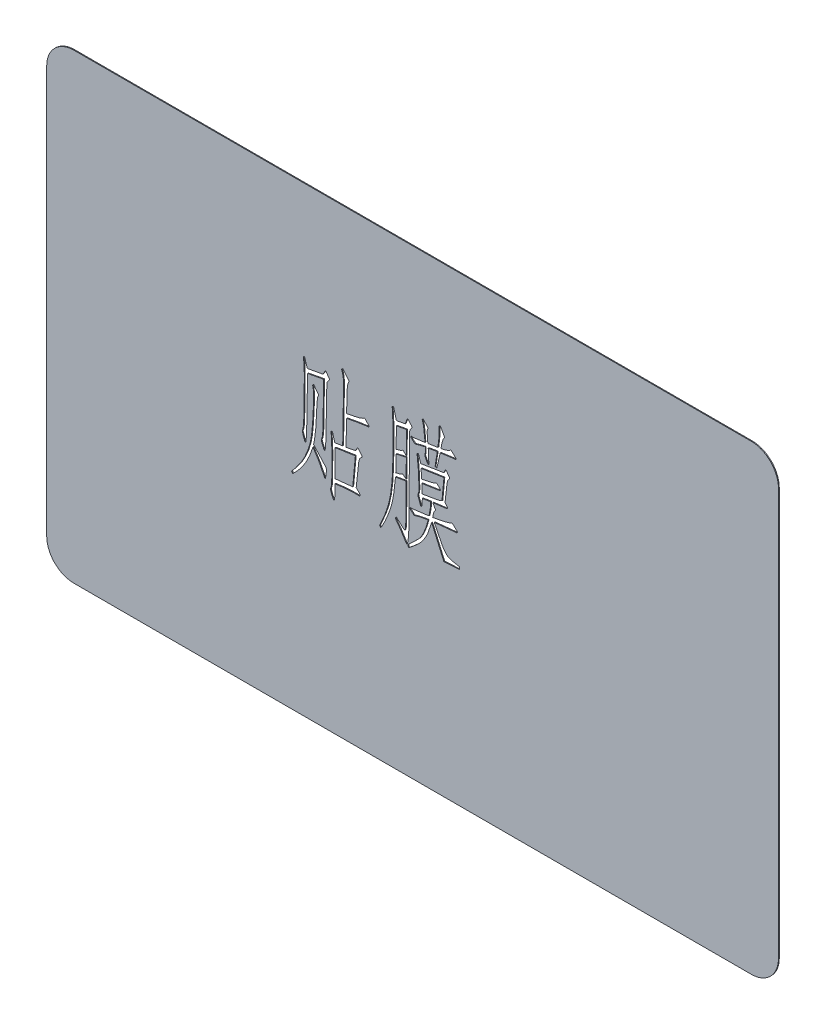
from build123d import *

# Parameters (mm, degrees)
SKETCH_1_W          = 85.6
SKETCH_1_H          = 54
EXTRUDE_1_DEPTH     = 0.1
CUT_EXTRUDE_1_DEPTH = 0.1
FILLET_1_R          = 3.18


with BuildPart() as part:
    # 草图1 → 凸台-拉伸1 (new body)
    with BuildSketch(Plane.XY):
        with Locations((42.8, 27)):
            Rectangle(SKETCH_1_W, SKETCH_1_H)
    extrude(amount=EXTRUDE_1_DEPTH)

    # 草图2 → 切除-拉伸1 (cut)
    with BuildSketch(Plane.XY.offset(0.1)):
        with BuildLine():
            add(Edge.make_bspline(
                [(28.656175286, 24.104684648), (28.735700661, 24.198459974), (28.881749684, 24.370679153), (29.062126573, 24.58276599), (29.199732619, 24.755647068), (29.315265517, 24.912190212), (29.448332239, 25.10102743), (29.540105047, 25.238763146), (29.589480208, 25.312867047)],
                knots=[0, 0, 0, 0, 0.000368874, 0.000677441, 0.00083518, 0.001031645, 0.001261024, 0.001528152, 0.001528152, 0.001528152, 0.001528152], degree=3))
            Line((29.589480208, 25.312867047), (29.864357685, 25.715594513))
            add(Edge.make_bspline(
                [(29.864357685, 25.715594513), (29.906887348, 25.785547825), (30.000429812, 25.939407619), (30.138312694, 26.199102298), (30.280447516, 26.509887767), (30.43607869, 26.856124558), (30.584143752, 27.224018132), (30.709708413, 27.597245925), (30.815624551, 27.962116542), (30.894534474, 28.327868731), (30.958548039, 28.702784693), (31.014348198, 29.099195432), (31.057998689, 29.522910676), (31.092383091, 29.960011392), (31.119951987, 30.382131357), (31.146398119, 30.761315297), (31.165954039, 31.083777027), (31.183160606, 31.447455053), (31.199052983, 31.89069414), (31.214535277, 32.339560662), (31.220062131, 32.707553797), (31.220737523, 32.967558953), (31.215142887, 33.204240258), (31.205136167, 33.353945216), (31.200390074, 33.424948871)],
                knots=[0, 0, 0, 0, 0.000245573, 0.00054013, 0.000881389, 0.001270609, 0.001678957, 0.002070457, 0.002451542, 0.002818101, 0.003192237, 0.003592425, 0.004018816, 0.004469878, 0.004907717, 0.005287866, 0.005610193, 0.005876854, 0.006380096, 0.006940764, 0.007224197, 0.007484159, 0.007720767, 0.007934234, 0.007934234, 0.007934234, 0.007934234], degree=3))
            add(Edge.make_bspline(
                [(31.200390074, 33.424948871), (31.198219884, 33.461875463), (31.194253739, 33.529360919), (31.189471877, 33.619814546), (31.180036791, 33.688498344), (31.174817472, 33.726817851), (31.172689243, 33.742443011)],
                knots=[0, 0, 0, 0, 0.000110988, 0.000202836, 0.000271553, 0.000318866, 0.000318866, 0.000318866, 0.000318866], degree=3))
            Line((31.172689243, 33.742443011), (31.100240915, 34.042890486))
            Line((31.100240915, 34.042890486), (31.215305906, 34.187787141))
            Line((31.215305906, 34.187787141), (31.820462522, 33.367416376))
            add(Edge.make_bspline(
                [(31.820462522, 33.367416376), (31.782372157, 33.304425092), (31.707013567, 33.179802123), (31.663999836, 32.961997333), (31.649619584, 32.739429401), (31.626069297, 32.543004009), (31.612596533, 32.362455698), (31.602121935, 32.189830645), (31.591583828, 31.98099499), (31.577900489, 31.654922207), (31.559860705, 31.223652206), (31.534362206, 30.791311554), (31.519528835, 30.457979141), (31.502729762, 30.232313446), (31.491849623, 30.029648298), (31.480566537, 29.902658024), (31.475267551, 29.843018336)],
                knots=[0, 0, 0, 0, 0.000219227, 0.000433723, 0.000656352, 0.000889792, 0.001026581, 0.001199507, 0.0014086, 0.001653878, 0.002178587, 0.002703503, 0.002953138, 0.003179498, 0.003382331, 0.003561941, 0.003561941, 0.003561941, 0.003561941], degree=3))
            Line((31.475267551, 29.843018336), (31.402819224, 29.210160889))
            add(Edge.make_bspline(
                [(31.402819224, 29.210160889), (31.3947528, 29.127708449), (31.380697761, 28.984042278), (31.357421776, 28.801175523), (31.346241979, 28.6818079), (31.334137534, 28.624856981), (31.330370896, 28.607135106)],
                knots=[0, 0, 0, 0, 0.000248496, 0.000432982, 0.000553237, 0.000607563, 0.000607563, 0.000607563, 0.000607563], degree=3))
            Line((31.330370896, 28.607135106), (31.215305906, 28.074426817))
            Line((31.215305906, 28.074426817), (31.647865037, 27.614166855))
            Line((31.647865037, 27.614166855), (32.135825829, 27.068673567))
            Line((32.135825829, 27.068673567), (32.625917455, 26.521049446))
            add(Edge.make_bspline(
                [(32.625917455, 26.521049446), (32.650826645, 26.489111521), (32.697625327, 26.429107451), (32.721468516, 26.31819724), (32.720973266, 26.206969609), (32.714567041, 26.131087138), (32.711150781, 26.090621149)],
                knots=[0, 0, 0, 0, 0.000119972, 0.0002254, 0.000331963, 0.000453719, 0.000453719, 0.000453719, 0.000453719], degree=3))
            Line((32.711150781, 26.090621149), (32.68344995, 25.745426178))
            Line((32.68344995, 25.745426178), (32.611001623, 25.385315374))
            add(Edge.make_bspline(
                [(32.611001623, 25.385315374), (32.60912093, 25.362192938), (32.606219456, 25.326520379), (32.556566728, 25.294397819), (32.51770981, 25.335818728), (32.50406919, 25.36682775), (32.495936632, 25.385315374)],
                knots=[0, 0, 0, 0, 6.674e-05, 0.000102964, 0.00014558, 0.000208503, 0.000208503, 0.000208503, 0.000208503], degree=3))
            Line((32.495936632, 25.385315374), (32.408572473, 25.572828692))
            add(Edge.make_bspline(
                [(32.408572473, 25.572828692), (32.399408194, 25.592749171), (32.378693042, 25.637777889), (32.342260204, 25.71226904), (32.297730421, 25.800808255), (32.246562043, 25.90307378), (32.189327612, 26.018650817), (32.122629388, 26.146889384), (32.047757735, 26.289136277), (31.940053767, 26.500979245), (31.794070174, 26.777969385), (31.59286763, 27.10947025), (31.379561986, 27.449951736), (31.222737893, 27.673100649), (31.142857579, 27.786764341)],
                knots=[0, 0, 0, 0, 6.578e-05, 0.000148691, 0.00024875, 0.000363102, 0.000491749, 0.000635655, 0.000796727, 0.000973984, 0.001348635, 0.001735632, 0.00213701, 0.002553706, 0.002553706, 0.002553706, 0.002553706], degree=3))
            add(Edge.make_bspline(
                [(31.142857579, 27.786764341), (31.081434308, 27.59056944), (30.961118473, 27.206263086), (30.741628986, 26.655290098), (30.5006678, 26.138704798), (30.227777655, 25.655367598), (29.924866596, 25.193313695), (29.578307092, 24.748208185), (29.196498086, 24.307510205), (28.914561069, 24.03035864), (28.771240276, 23.889470499)],
                knots=[0, 0, 0, 0, 0.000616562, 0.001207722, 0.001777735, 0.002325371, 0.002871451, 0.003433611, 0.004016526, 0.004619224, 0.004619224, 0.004619224, 0.004619224], degree=3))
            Line((28.771240276, 23.889470499), (28.656175286, 24.104684648))
        make_face()
        with BuildLine():
            Line((30.007123507, 36.344190294), (30.152020161, 36.459255285))
            Line((30.152020161, 36.459255285), (30.497215132, 35.410885372))
            Line((30.497215132, 35.410885372), (32.308423315, 35.741164511))
            Line((32.308423315, 35.741164511), (32.553469128, 36.15880781))
            add(Edge.make_bspline(
                [(32.553469128, 36.15880781), (32.560174629, 36.172108302), (32.571906115, 36.195377936), (32.602200299, 36.221016825), (32.640332926, 36.21309835), (32.658116652, 36.196330828), (32.668534118, 36.186508641)],
                knots=[0, 0, 0, 0, 4.495e-05, 7.8641e-05, 0.000108776, 0.000151393, 0.000151393, 0.000151393, 0.000151393], degree=3))
            Line((32.668534118, 36.186508641), (33.04142992, 35.698547848))
            add(Edge.make_bspline(
                [(33.04142992, 35.698547848), (33.050213561, 35.683317124), (33.068447412, 35.651699851), (33.063174347, 35.59630499), (33.055547457, 35.542522288), (33.037504573, 35.511400515), (33.028644921, 35.496118698)],
                knots=[0, 0, 0, 0, 5.1494e-05, 0.000106896, 0.000161221, 0.000213633, 0.000213633, 0.000213633, 0.000213633], degree=3))
            Line((33.028644921, 35.496118698), (32.913579931, 35.353352877))
            add(Edge.make_bspline(
                [(32.913579931, 35.353352877), (32.89544698, 35.33058021), (32.858226066, 35.283835505), (32.821869037, 35.198445726), (32.792182146, 35.103809453), (32.781917528, 34.991266296), (32.777304751, 34.854746089), (32.766764145, 34.682940145), (32.762574379, 34.470447225), (32.756868216, 34.314919003), (32.753767444, 34.230403804)],
                knots=[0, 0, 0, 0, 8.6947e-05, 0.000178474, 0.000276237, 0.000383543, 0.00051581, 0.000686489, 0.000899668, 0.001153381, 0.001153381, 0.001153381, 0.001153381], degree=3))
            Line((32.753767444, 34.230403804), (32.668534118, 29.642720019))
            Line((32.668534118, 29.642720019), (32.638702454, 28.837265087))
            Line((32.638702454, 28.837265087), (32.611001623, 28.519770946))
            Line((32.611001623, 28.519770946), (32.581169959, 28.247024302))
            add(Edge.make_bspline(
                [(32.581169959, 28.247024302), (32.57631288, 28.213730268), (32.568989857, 28.163532819), (32.526779837, 28.08454232), (32.456016144, 28.131709123), (32.436488559, 28.175352552), (32.423488305, 28.204407639)],
                knots=[0, 0, 0, 0, 0.000107496, 0.000162072, 0.000211634, 0.000310345, 0.000310345, 0.000310345, 0.000310345], degree=3))
            Line((32.423488305, 28.204407639), (32.338254979, 28.391920957))
            Line((32.338254979, 28.391920957), (32.25089082, 28.592219274))
            Line((32.25089082, 28.592219274), (32.178442492, 28.779732591))
            Line((32.178442492, 28.779732591), (32.150741661, 28.894797582))
            add(Edge.make_bspline(
                [(32.150741661, 28.894797582), (32.142324743, 28.9156871), (32.128577849, 28.949804813), (32.124573642, 28.996247725), (32.134922254, 29.032471984), (32.150616146, 29.071421318), (32.16904938, 29.125961146), (32.196522349, 29.19345219), (32.220676759, 29.278415469), (32.245532961, 29.379625219), (32.260736277, 29.498258529), (32.272325671, 29.627012341), (32.282603183, 29.753490974), (32.290396159, 29.865113255), (32.298594887, 29.955388097), (32.305452437, 30.007817718), (32.308423315, 30.030531654)],
                knots=[0, 0, 0, 0, 6.7383e-05, 0.000110053, 0.00013641, 0.000179556, 0.000236173, 0.000308997, 0.000397983, 0.000500839, 0.000621377, 0.000756227, 0.000888767, 0.001002022, 0.001091922, 0.00116064, 0.00116064, 0.00116064, 0.00116064], degree=3))
            Line((32.308423315, 30.030531654), (32.36595581, 33.179903058))
            Line((32.36595581, 33.179903058), (32.380871642, 35.265988717))
            Line((32.380871642, 35.265988717), (30.524915963, 34.920793746))
            Line((30.524915963, 34.920793746), (30.439682637, 31.095948232))
            Line((30.439682637, 31.095948232), (30.424766805, 29.75778501))
            Line((30.424766805, 29.75778501), (30.382150142, 28.564518443))
            Line((30.382150142, 28.564518443), (30.352318478, 28.189491807))
            Line((30.352318478, 28.189491807), (30.337402646, 27.974277658))
            add(Edge.make_bspline(
                [(30.337402646, 27.974277658), (30.334811121, 27.94450863), (30.330607715, 27.896223808), (30.276213856, 27.837232075), (30.209136913, 27.876189118), (30.190916031, 27.91846896), (30.179720992, 27.944445994)],
                knots=[0, 0, 0, 0, 8.9925e-05, 0.000145857, 0.000199298, 0.000284451, 0.000284451, 0.000284451, 0.000284451], degree=3))
            Line((30.179720992, 27.944445994), (30.094487666, 28.161790976))
            Line((30.094487666, 28.161790976), (29.992207674, 28.404705956))
            Line((29.992207674, 28.404705956), (29.964506843, 28.54960261))
            Line((29.964506843, 28.54960261), (29.92189018, 28.664667601))
            add(Edge.make_bspline(
                [(29.92189018, 28.664667601), (29.914395771, 28.686453668), (29.901530078, 28.723853922), (29.887146995, 28.784206072), (29.908033844, 28.855025262), (29.944886418, 28.946630012), (29.992352397, 29.067010727), (30.01644413, 29.223792517), (30.038976205, 29.419111216), (30.050118165, 29.664054103), (30.065436184, 29.950928128), (30.074741352, 30.154818454), (30.079571834, 30.260661635)],
                knots=[0, 0, 0, 0, 6.9408e-05, 0.000119152, 0.000182255, 0.000284757, 0.000418202, 0.000567817, 0.000758654, 0.001008407, 0.00130284, 0.001620685, 0.001620685, 0.001620685, 0.001620685], degree=3))
            Line((30.079571834, 30.260661635), (30.107272665, 31.814039005))
            Line((30.107272665, 31.814039005), (30.137104329, 34.475449617))
            add(Edge.make_bspline(
                [(30.137104329, 34.475449617), (30.137562541, 34.557136394), (30.138431229, 34.711999903), (30.132696615, 34.93002434), (30.129654746, 35.121145899), (30.122464673, 35.285889196), (30.11663258, 35.42655222), (30.109418313, 35.543674851), (30.105634735, 35.638193564), (30.101277537, 35.722132504), (30.090704562, 35.819436499), (30.074556347, 35.952635), (30.042163727, 36.132460611), (30.019705962, 36.268161112), (30.007123507, 36.344190294)],
                knots=[0, 0, 0, 0, 0.000245046, 0.000464563, 0.000654255, 0.000818454, 0.000959234, 0.001076604, 0.001170457, 0.001243031, 0.001328689, 0.00146401, 0.001645469, 0.001876672, 0.001876672, 0.001876672, 0.001876672], degree=3))
        make_face()
        with BuildLine():
            Line((33.271559901, 30.448174952), (33.416456556, 30.505707447))
            Line((33.416456556, 30.505707447), (33.704119032, 29.485038366))
            Line((33.704119032, 29.485038366), (34.624638955, 29.642720019))
            Line((34.624638955, 29.642720019), (34.724788113, 35.481202866))
            add(Edge.make_bspline(
                [(34.724788113, 35.481202866), (34.726195142, 35.574957646), (34.728795925, 35.748255977), (34.732579637, 35.987643104), (34.728388993, 36.184483567), (34.717883513, 36.385157463), (34.694326876, 36.592399656), (34.654448183, 36.824874924), (34.591559143, 37.066709254), (34.529172219, 37.23122711), (34.494658133, 37.322242713)],
                knots=[0, 0, 0, 0, 0.000281302, 0.000519965, 0.000718178, 0.000871835, 0.001122677, 0.00134338, 0.001579056, 0.001870887, 0.001870887, 0.001870887, 0.001870887], degree=3))
            Line((34.494658133, 37.322242713), (34.624638955, 37.467139367))
            Line((34.624638955, 37.467139367), (35.372561393, 36.561535276))
            add(Edge.make_bspline(
                [(35.372561393, 36.561535276), (35.346101414, 36.503657871), (35.295155456, 36.392220906), (35.236088637, 36.226019638), (35.191444426, 36.070482307), (35.16794194, 35.918660464), (35.156369721, 35.760453192), (35.146216997, 35.584223221), (35.134841211, 35.383270139), (35.13005267, 35.241142423), (35.12751558, 35.165839559)],
                knots=[0, 0, 0, 0, 0.000190826, 0.000367415, 0.000528698, 0.000675478, 0.000827307, 0.001004486, 0.001205068, 0.001431097, 0.001431097, 0.001431097, 0.001431097], degree=3))
            Line((35.12751558, 35.165839559), (35.084898917, 33.137286395))
            Line((35.084898917, 33.137286395), (36.033119671, 33.324799713))
            add(Edge.make_bspline(
                [(36.033119671, 33.324799713), (36.103553447, 33.33919553), (36.237792625, 33.366632404), (36.428813369, 33.414187357), (36.601062005, 33.462430212), (36.754738872, 33.513362738), (36.889620656, 33.565971072), (37.005322441, 33.622048877), (37.104371968, 33.677049388), (37.158719257, 33.721811016), (37.183769575, 33.742443011)],
                knots=[0, 0, 0, 0, 0.000215646, 0.000410998, 0.000590419, 0.000752138, 0.000896564, 0.001024272, 0.001137927, 0.001235108, 0.001235108, 0.001235108, 0.001235108], degree=3))
            Line((37.183769575, 33.742443011), (37.644029537, 33.252351385))
            add(Edge.make_bspline(
                [(37.644029537, 33.252351385), (37.660197339, 33.230708864), (37.688907708, 33.192276629), (37.702511374, 33.126975625), (37.674514301, 33.069930017), (37.636761086, 33.06662615), (37.616328706, 33.064838068)],
                knots=[0, 0, 0, 0, 8.0409e-05, 0.000142788, 0.000191425, 0.0002488, 0.0002488, 0.0002488, 0.0002488], degree=3))
            Line((37.616328706, 33.064838068), (37.386198725, 33.037137237))
            Line((37.386198725, 33.037137237), (36.307997148, 32.879455583))
            Line((36.307997148, 32.879455583), (35.084898917, 32.649325602))
            Line((35.084898917, 32.649325602), (35.012450589, 29.685336683))
            Line((35.012450589, 29.685336683), (36.105567998, 29.900550831))
            Line((36.105567998, 29.900550831), (36.320782147, 30.245745802))
            add(Edge.make_bspline(
                [(36.320782147, 30.245745802), (36.329484245, 30.259504639), (36.345356186, 30.284599672), (36.385489684, 30.306432104), (36.429937137, 30.292754193), (36.452434133, 30.272554066), (36.465678802, 30.260661635)],
                knots=[0, 0, 0, 0, 4.859e-05, 8.8625e-05, 0.000125839, 0.000179109, 0.000179109, 0.000179109, 0.000179109], degree=3))
            Line((36.465678802, 30.260661635), (36.838574604, 29.800401673))
            add(Edge.make_bspline(
                [(36.838574604, 29.800401673), (36.858060682, 29.773850999), (36.889310125, 29.731272202), (36.904191593, 29.66310264), (36.878735877, 29.622804044), (36.84701538, 29.585606899), (36.798296235, 29.537924753), (36.711899259, 29.461062886), (36.604748701, 29.334552661), (36.535655104, 29.127123362), (36.495133143, 28.881860969), (36.476052532, 28.703892729), (36.465678802, 28.607135106)],
                knots=[0, 0, 0, 0, 9.9398e-05, 0.000159403, 0.000190864, 0.000237791, 0.000307101, 0.000394543, 0.000585559, 0.000795302, 0.001040209, 0.001332001, 0.001332001, 0.001332001, 0.001332001], degree=3))
            Line((36.465678802, 28.607135106), (36.205717157, 26.190770307))
            Line((36.205717157, 26.190770307), (36.638276287, 25.758211176))
            add(Edge.make_bspline(
                [(36.638276287, 25.758211176), (36.649431735, 25.735246803), (36.671280824, 25.690268721), (36.670950334, 25.628095779), (36.656357102, 25.580080991), (36.620886969, 25.55970234), (36.577317955, 25.543596439), (36.542655543, 25.543212437), (36.523211297, 25.542997028)],
                knots=[0, 0, 0, 0, 7.5577e-05, 0.000148025, 0.00018245, 0.00021911, 0.000264262, 0.000321952, 0.000321952, 0.000321952, 0.000321952], degree=3))
            Line((36.523211297, 25.542997028), (35.775288859, 25.542997028))
            Line((35.775288859, 25.542997028), (34.854768936, 25.485464533))
            Line((34.854768936, 25.485464533), (33.731819863, 25.342698711))
            Line((33.731819863, 25.342698711), (33.704119032, 24.089768815))
            Line((33.704119032, 24.089768815), (33.674287368, 23.817022172))
            add(Edge.make_bspline(
                [(33.674287368, 23.817022172), (33.670471885, 23.791383445), (33.663841481, 23.746829414), (33.650079718, 23.690182124), (33.633200919, 23.653097058), (33.606875698, 23.633798797), (33.576247885, 23.645096569), (33.550390327, 23.676853343), (33.518743087, 23.725520894), (33.499686513, 23.766267916), (33.488904883, 23.789321341)],
                knots=[0, 0, 0, 0, 7.7768e-05, 0.000135143, 0.000174259, 0.000199109, 0.000223404, 0.000262579, 0.00032109, 0.000397325, 0.000397325, 0.000397325, 0.000397325], degree=3))
            Line((33.488904883, 23.789321341), (33.386624892, 23.974703825))
            Line((33.386624892, 23.974703825), (33.286475733, 24.219749638))
            Line((33.286475733, 24.219749638), (33.228943238, 24.422178788))
            add(Edge.make_bspline(
                [(33.228943238, 24.422178788), (33.217948146, 24.450020778), (33.20067791, 24.49375281), (33.187310079, 24.561290174), (33.216541616, 24.627776093), (33.247140473, 24.719523566), (33.287948476, 24.843265023), (33.308723137, 24.991471058), (33.326609702, 25.145181786), (33.338344897, 25.248223789), (33.344008228, 25.297951215)],
                knots=[0, 0, 0, 0, 9.0303e-05, 0.000141841, 0.000199806, 0.000301574, 0.000435054, 0.000588488, 0.000749447, 0.000899577, 0.000899577, 0.000899577, 0.000899577], degree=3))
            Line((33.344008228, 25.297951215), (33.344008228, 25.630361187))
            Line((33.344008228, 25.630361187), (33.358924061, 26.248302802))
            Line((33.358924061, 26.248302802), (33.358924061, 27.168822726))
            Line((33.358924061, 27.168822726), (33.373839893, 28.347173461))
            add(Edge.make_bspline(
                [(33.373839893, 28.347173461), (33.373172347, 28.411807907), (33.37174913, 28.549609397), (33.368542824, 28.769891573), (33.356092384, 29.016971504), (33.339798862, 29.384282602), (33.313588119, 29.864606426), (33.28562445, 30.252886441), (33.271559901, 30.448174952)],
                knots=[0, 0, 0, 0, 0.000193918, 0.000413435, 0.000660841, 0.000936016, 0.001516483, 0.002103859, 0.002103859, 0.002103859, 0.002103859], degree=3))
        make_face()
        Polygon((33.731819863, 25.860491168), (35.80298969, 26.075705317), (36.105567998, 29.369973375), (33.731819863, 29.009862572), align=None, mode=Mode.SUBTRACT)
        with BuildLine():
            add(Edge.make_bspline(
                [(42.242367487, 23.429210537), (42.363684025, 23.545131076), (42.591424794, 23.762742238), (42.913132466, 24.065987061), (43.183415648, 24.334183395), (43.424726984, 24.563246574), (43.632416621, 24.79307591), (43.815726619, 25.045928336), (43.981714032, 25.329211686), (44.132518932, 25.641248308), (44.268750163, 25.981638235), (44.402282036, 26.344416045), (44.519912336, 26.733832567), (44.591973133, 27.001714971), (44.628900621, 27.138991061)],
                knots=[0, 0, 0, 0, 0.000503391, 0.000944988, 0.001326216, 0.001645657, 0.001942944, 0.002254075, 0.002580781, 0.002926719, 0.003292738, 0.003680322, 0.004086076, 0.004512552, 0.004512552, 0.004512552, 0.004512552], degree=3))
            add(Edge.make_bspline(
                [(44.628900621, 27.138991061), (44.5799344, 27.128824197), (44.473676168, 27.106761783), (44.302059792, 27.076389987), (44.107154805, 27.038508977), (43.814318417, 26.989931504), (43.430073824, 26.912316903), (43.128006254, 26.815178476), (42.975374093, 26.766095259)],
                knots=[0, 0, 0, 0, 0.000150023, 0.000325555, 0.000522816, 0.000745618, 0.001216199, 0.001696847, 0.001696847, 0.001696847, 0.001696847], degree=3))
            Line((42.975374093, 26.766095259), (42.542814962, 27.168822726))
            add(Edge.make_bspline(
                [(42.542814962, 27.168822726), (42.523019768, 27.18420568), (42.485201604, 27.213594385), (42.485256368, 27.261200236), (42.485282467, 27.283887716)],
                knots=[0, 0, 0, 0, 7.0832e-05, 0.000135323, 0.000135323, 0.000135323, 0.000135323], degree=3))
            add(Edge.make_bspline(
                [(42.485282467, 27.283887716), (42.490170352, 27.293343773), (42.502992008, 27.318148428), (42.547830595, 27.326666321), (42.598530037, 27.333805704), (42.662740028, 27.343244507), (42.747295382, 27.348361667), (42.833462202, 27.352453499), (42.921366154, 27.361597878), (43.01243525, 27.369287111), (43.125346818, 27.382500785), (43.259424915, 27.400135915), (43.415844602, 27.418773263), (43.59412883, 27.442234553), (43.794938976, 27.470682727), (43.936362101, 27.489288054), (44.010959006, 27.499101865)],
                knots=[0, 0, 0, 0, 3.0731e-05, 8.0613e-05, 0.000123706, 0.000188197, 0.00027367, 0.000378276, 0.000446762, 0.000538783, 0.000652439, 0.000787759, 0.000944488, 0.001125006, 0.001327211, 0.001552928, 0.001552928, 0.001552928, 0.001552928], degree=3))
            Line((44.010959006, 27.499101865), (44.72904978, 27.599251023))
            add(Edge.make_bspline(
                [(44.72904978, 27.599251023), (44.752128997, 27.727042542), (44.797601233, 27.978826039), (44.84817575, 28.287295402), (44.884574578, 28.515130197), (44.900728223, 28.656713019), (44.912702566, 28.770318448), (44.915403508, 28.836536618), (44.916563097, 28.864965918)],
                knots=[0, 0, 0, 0, 0.000389564, 0.000767545, 0.000937812, 0.001081592, 0.001195027, 0.001280367, 0.001280367, 0.001280367, 0.001280367], degree=3))
            Line((44.916563097, 28.864965918), (44.916563097, 29.124927563))
            Line((44.916563097, 29.124927563), (43.938510679, 28.967245909))
            Line((43.938510679, 28.967245909), (43.910809848, 28.334388462))
            add(Edge.make_bspline(
                [(43.910809848, 28.334388462), (43.903260861, 28.297718777), (43.886773984, 28.217632718), (43.852877509, 28.135522645), (43.827938038, 28.078026721), (43.803612536, 28.06921139), (43.780227971, 28.082118011), (43.760420077, 28.110797043), (43.734697696, 28.153169469), (43.707391189, 28.21313216), (43.68129378, 28.290320462), (43.66156676, 28.346487245), (43.650848203, 28.377005125)],
                knots=[0, 0, 0, 0, 0.00011164, 0.000243821, 0.000271603, 0.000291818, 0.000312804, 0.000346089, 0.000395788, 0.000461569, 0.000543127, 0.000640167, 0.000640167, 0.000640167, 0.000640167], degree=3))
            Line((43.650848203, 28.377005125), (43.550699045, 28.649751769))
            add(Edge.make_bspline(
                [(43.550699045, 28.649751769), (43.529499644, 28.703579182), (43.492311371, 28.798003951), (43.451477117, 28.92171141), (43.421119344, 29.00635369), (43.420821505, 29.051677879), (43.420718222, 29.067395067)],
                knots=[0, 0, 0, 0, 0.000173333, 0.000304062, 0.00039246, 0.000439386, 0.000439386, 0.000439386, 0.000439386], degree=3))
            add(Edge.make_bspline(
                [(43.420718222, 29.067395067), (43.42198136, 29.075245677), (43.425603559, 29.097758231), (43.439994443, 29.139146184), (43.458743542, 29.200547907), (43.487870679, 29.281055019), (43.519252664, 29.384529491), (43.535459423, 29.515218366), (43.549039063, 29.670124813), (43.550118932, 29.782597345), (43.550699045, 29.843018336)],
                knots=[0, 0, 0, 0, 2.3823e-05, 6.8317e-05, 0.000130986, 0.000216565, 0.000325154, 0.000454434, 0.00061051, 0.000791681, 0.000791681, 0.000791681, 0.000791681], degree=3))
            Line((43.550699045, 29.843018336), (43.478250717, 31.613740688))
            add(Edge.make_bspline(
                [(43.478250717, 31.613740688), (43.475453889, 31.650678565), (43.468835992, 31.738081533), (43.456262477, 31.887263773), (43.438124597, 32.074617273), (43.414395403, 32.371867473), (43.376236548, 32.759914163), (43.33885388, 33.072000946), (43.320569064, 33.224650554)],
                knots=[0, 0, 0, 0, 0.000111131, 0.000262959, 0.000449124, 0.000675805, 0.001157528, 0.001618744, 0.001618744, 0.001618744, 0.001618744], degree=3))
            Line((43.320569064, 33.224650554), (43.478250717, 33.30988388))
            Line((43.478250717, 33.30988388), (43.750997361, 32.404279789))
            Line((43.750997361, 32.404279789), (45.736933862, 32.719643096))
            add(Edge.make_bspline(
                [(45.736933862, 32.719643096), (45.790217838, 32.727368292), (45.88973, 32.741795723), (46.028918858, 32.763291129), (46.148275495, 32.782309976), (46.247604772, 32.799306902), (46.326965975, 32.813266228), (46.387219043, 32.819767042), (46.427271434, 32.829292532), (46.447915618, 32.833320886), (46.455024636, 32.834708087)],
                knots=[0, 0, 0, 0, 0.000161522, 0.000301656, 0.000422514, 0.000524103, 0.000603974, 0.000664243, 0.000705616, 0.000727347, 0.000727347, 0.000727347, 0.000727347], degree=3))
            Line((46.455024636, 32.834708087), (46.59992129, 33.167118059))
            add(Edge.make_bspline(
                [(46.59992129, 33.167118059), (46.608169833, 33.187151567), (46.621704235, 33.220023018), (46.668644028, 33.248816368), (46.721203651, 33.228090851), (46.743898661, 33.198045695), (46.757602944, 33.179903058)],
                knots=[0, 0, 0, 0, 6.396e-05, 0.000104948, 0.000149441, 0.00021726, 0.00021726, 0.00021726, 0.00021726], degree=3))
            Line((46.757602944, 33.179903058), (47.075097084, 32.719643096))
            Line((47.075097084, 32.719643096), (47.117713747, 32.649325602))
            add(Edge.make_bspline(
                [(47.117713747, 32.649325602), (47.121891354, 32.640147985), (47.12948412, 32.623467742), (47.143180788, 32.595450895), (47.129950592, 32.552613096), (47.113572754, 32.523549582), (47.102797915, 32.504428948)],
                knots=[0, 0, 0, 0, 3.0509e-05, 5.545e-05, 9.0137e-05, 0.000156843, 0.000156843, 0.000156843, 0.000156843], degree=3))
            Line((47.102797915, 32.504428948), (47.002648757, 32.419195621))
            add(Edge.make_bspline(
                [(47.002648757, 32.419195621), (46.983259393, 32.389875693), (46.938355827, 32.321974065), (46.896556203, 32.216126854), (46.86337703, 32.097189812), (46.840449552, 31.962731431), (46.811716054, 31.787551103), (46.796083602, 31.65644585), (46.787434608, 31.583909024)],
                knots=[0, 0, 0, 0, 0.000105255, 0.00024376, 0.000338886, 0.000475542, 0.000652453, 0.000871556, 0.000871556, 0.000871556, 0.000871556], degree=3))
            Line((46.787434608, 31.583909024), (46.59992129, 29.87285))
            Line((46.59992129, 29.87285), (46.815135439, 29.612888355))
            add(Edge.make_bspline(
                [(46.815135439, 29.612888355), (46.828720722, 29.593418688), (46.853080953, 29.558506968), (46.87527666, 29.506561613), (46.89202946, 29.464833998), (46.88987204, 29.420995855), (46.859599818, 29.375924667), (46.82087178, 29.372043208), (46.800219607, 29.369973375)],
                knots=[0, 0, 0, 0, 7.0928e-05, 0.000127184, 0.00016964, 0.0002038, 0.000255821, 0.000315255, 0.000315255, 0.000315255, 0.000315255], degree=3))
            Line((46.800219607, 29.369973375), (46.627622122, 29.340141711))
            add(Edge.make_bspline(
                [(46.627622122, 29.340141711), (46.610593009, 29.337187691), (46.565350338, 29.329339498), (46.480765632, 29.319219819), (46.363300496, 29.30994716), (46.211429798, 29.293656631), (46.017893974, 29.275488361), (45.777011205, 29.245051273), (45.486153875, 29.20127376), (45.275254958, 29.169662562), (45.16160891, 29.152628394)],
                knots=[0, 0, 0, 0, 5.1845e-05, 0.000137742, 0.000255421, 0.000405323, 0.000595935, 0.00083856, 0.001133578, 0.001478326, 0.001478326, 0.001478326, 0.001478326], degree=3))
            Line((45.16160891, 29.152628394), (45.491888049, 28.577303442))
            add(Edge.make_bspline(
                [(45.491888049, 28.577303442), (45.467299906, 28.541358808), (45.421660066, 28.474639362), (45.364061363, 28.377100488), (45.317008435, 28.294024464), (45.280281221, 28.214583532), (45.250344555, 28.122475204), (45.223595127, 28.000336701), (45.182225305, 27.842412498), (45.15937262, 27.723024523), (45.146693078, 27.656783518)],
                knots=[0, 0, 0, 0, 0.000130608, 0.000242431, 0.000339705, 0.000416946, 0.000504544, 0.000629611, 0.000791891, 0.000994152, 0.000994152, 0.000994152, 0.000994152], degree=3))
            Line((45.146693078, 27.656783518), (45.981979675, 27.801680173))
            add(Edge.make_bspline(
                [(45.981979675, 27.801680173), (46.063741494, 27.816175692), (46.221220354, 27.844095054), (46.44714012, 27.891124498), (46.65495304, 27.93962801), (46.842733387, 27.991975131), (47.011064697, 28.048087025), (47.159818244, 28.105210311), (47.291469487, 28.163305018), (47.368844634, 28.210042177), (47.405376223, 28.23210847)],
                knots=[0, 0, 0, 0, 0.000249098, 0.00047978, 0.000692201, 0.000889185, 0.001064381, 0.00122425, 0.00136727, 0.001495191, 0.001495191, 0.001495191, 0.001495191], degree=3))
            Line((47.405376223, 28.23210847), (47.980701175, 27.714316013))
            add(Edge.make_bspline(
                [(47.980701175, 27.714316013), (48.00089187, 27.692344392), (48.038148927, 27.651801066), (48.035218213, 27.574828814), (48.007375101, 27.512890814), (47.968750291, 27.503465277), (47.950869511, 27.499101865)],
                knots=[0, 0, 0, 0, 8.5711e-05, 0.00015816, 0.000219215, 0.000271842, 0.000271842, 0.000271842, 0.000271842], degree=3))
            Line((47.950869511, 27.499101865), (47.750571195, 27.484186033))
            add(Edge.make_bspline(
                [(47.750571195, 27.484186033), (47.725710926, 27.482063129), (47.653949949, 27.475935212), (47.513909088, 27.463587477), (47.3089592, 27.44045766), (47.038694205, 27.417103516), (46.704390133, 27.381325405), (46.305021792, 27.342013439), (45.841509449, 27.291522837), (45.510386697, 27.258722898), (45.334206396, 27.241271053)],
                knots=[0, 0, 0, 0, 7.4853e-05, 0.000216068, 0.000421734, 0.000693556, 0.001029829, 0.001430346, 0.001897446, 0.002428571, 0.002428571, 0.002428571, 0.002428571], degree=3))
            add(Edge.make_bspline(
                [(45.334206396, 27.241271053), (45.401060617, 27.103521162), (45.52824939, 26.841454844), (45.708163964, 26.467259041), (45.875088452, 26.136619361), (46.020500724, 25.845234347), (46.153867438, 25.598720806), (46.266152383, 25.391270079), (46.360879244, 25.224987992), (46.462993621, 25.063506901), (46.582382322, 24.905356209), (46.723330337, 24.746490078), (46.867208988, 24.621088467), (46.993029829, 24.537994599), (47.106259729, 24.486633442), (47.211743124, 24.448512823), (47.339304022, 24.411000674), (47.488613415, 24.372908441), (47.659180887, 24.334674104), (47.851980968, 24.29707141), (48.066066418, 24.255504746), (48.217133986, 24.232020039), (48.296064482, 24.219749638)],
                knots=[0, 0, 0, 0, 0.000459351, 0.000873907, 0.001245552, 0.00157051, 0.001850777, 0.002086309, 0.00227819, 0.002424785, 0.002659176, 0.002871887, 0.003060715, 0.003230354, 0.00332188, 0.003433113, 0.003566593, 0.003720603, 0.003895332, 0.004090905, 0.004309894, 0.004549506, 0.004549506, 0.004549506, 0.004549506], degree=3))
            Line((48.296064482, 24.219749638), (48.283279484, 23.932087162))
            Line((48.283279484, 23.932087162), (46.455024636, 23.831938004))
            add(Edge.make_bspline(
                [(46.455024636, 23.831938004), (46.401694358, 23.953369474), (46.299122302, 24.186923018), (46.151973414, 24.524562661), (46.01598878, 24.835125417), (45.890512668, 25.118639835), (45.774970008, 25.373807619), (45.672782837, 25.602878645), (45.581259636, 25.804323097), (45.477668831, 26.033475494), (45.363870734, 26.290840449), (45.236375862, 26.575718794), (45.128813745, 26.837211334), (45.06273832, 27.003272255), (45.031628088, 27.081458566)],
                knots=[0, 0, 0, 0, 0.000397879, 0.000765254, 0.001104933, 0.001414968, 0.001695365, 0.001945254, 0.002167454, 0.002359146, 0.002699687, 0.00301167, 0.003295399, 0.003547847, 0.003547847, 0.003547847, 0.003547847], degree=3))
            add(Edge.make_bspline(
                [(45.031628088, 27.081458566), (44.969944279, 26.888247863), (44.851020397, 26.515745463), (44.701687857, 26.052995343), (44.557585397, 25.691452779), (44.418540888, 25.405238463), (44.241210106, 25.102234116), (44.073903895, 24.834741231), (43.912080174, 24.610398987), (43.763190443, 24.429836309), (43.586946739, 24.243255938), (43.388485909, 24.045731837), (43.162078498, 23.842997911), (42.912505439, 23.62923494), (42.637399113, 23.407662953), (42.443057684, 23.260367098), (42.342516645, 23.184164724)],
                knots=[0, 0, 0, 0, 0.000608512, 0.001173187, 0.001458082, 0.001775433, 0.002126685, 0.002510903, 0.002721457, 0.002956091, 0.003212394, 0.003491142, 0.003795873, 0.004123835, 0.004476917, 0.004855373, 0.004855373, 0.004855373, 0.004855373], degree=3))
            Line((42.342516645, 23.184164724), (42.242367487, 23.429210537))
        make_face()
        with BuildLine():
            Line((43.853277353, 30.893519082), (44.4861348, 31.008584072))
            add(Edge.make_bspline(
                [(44.4861348, 31.008584072), (44.55150077, 31.021239864), (44.676767849, 31.045493371), (44.857182375, 31.082541037), (45.019999131, 31.12627499), (45.168071464, 31.167233952), (45.298152043, 31.214206551), (45.41076182, 31.263563436), (45.509329006, 31.31133582), (45.565451832, 31.350257623), (45.592037208, 31.368694876)],
                knots=[0, 0, 0, 0, 0.000199754, 0.000382807, 0.000552325, 0.000705405, 0.000843581, 0.00096669, 0.001074376, 0.0011713, 0.0011713, 0.0011713, 0.0011713], degree=3))
            Line((45.592037208, 31.368694876), (45.994764674, 30.99366824))
            add(Edge.make_bspline(
                [(45.994764674, 30.99366824), (46.015128669, 30.97252938), (46.051783859, 30.934479433), (46.076589338, 30.861629642), (46.042288573, 30.792124556), (45.994733433, 30.78348244), (45.967063843, 30.778454091)],
                knots=[0, 0, 0, 0, 8.7857e-05, 0.000158142, 0.000215318, 0.000294875, 0.000294875, 0.000294875, 0.000294875], degree=3))
            Line((45.967063843, 30.778454091), (43.880978184, 30.463090784))
            Line((43.880978184, 30.463090784), (43.910809848, 29.412590039))
            Line((43.910809848, 29.412590039), (45.549420545, 29.685336683))
            add(Edge.make_bspline(
                [(45.549420545, 29.685336683), (45.61993571, 29.69793444), (45.753223716, 29.721746764), (45.938814887, 29.76905033), (46.100695608, 29.819702457), (46.195505001, 29.866088921), (46.239810487, 29.887765832)],
                knots=[0, 0, 0, 0, 0.000214802, 0.00040602, 0.000574477, 0.000722259, 0.000722259, 0.000722259, 0.000722259], degree=3))
            Line((46.239810487, 29.887765832), (46.469940468, 32.346747294))
            Line((46.469940468, 32.346747294), (43.795744858, 31.944019828))
            Line((43.795744858, 31.944019828), (43.853277353, 30.893519082))
        make_face(mode=Mode.SUBTRACT)
        with BuildLine():
            add(Edge.make_bspline(
                [(38.948099428, 23.744573844), (38.99660954, 23.848887587), (39.091769871, 24.053515653), (39.227487368, 24.354671317), (39.353928652, 24.643774033), (39.470484901, 24.919350591), (39.578360636, 25.182383315), (39.673206272, 25.433825342), (39.761439026, 25.67194702), (39.863840291, 25.974381715), (39.977546743, 26.349722891), (40.091059184, 26.808128798), (40.191564697, 27.278039044), (40.263196953, 27.751219732), (40.32331083, 28.204734761), (40.373309764, 28.616573788), (40.407853907, 28.977541167), (40.436277741, 29.395936479), (40.456399178, 29.899693355), (40.466480686, 30.300424928), (40.471645135, 30.505707447)],
                knots=[0, 0, 0, 0, 0.000345123, 0.000677013, 0.000990948, 0.001291728, 0.001574647, 0.001843749, 0.00209789, 0.00233643, 0.002801567, 0.003273925, 0.003752846, 0.00424259, 0.004709091, 0.005125368, 0.005487089, 0.005796794, 0.006383331, 0.006999377, 0.006999377, 0.006999377, 0.006999377], degree=3))
            Line((40.471645135, 30.505707447), (40.501476799, 31.583909024))
            Line((40.501476799, 31.583909024), (40.52917763, 33.109585564))
            add(Edge.make_bspline(
                [(40.52917763, 33.109585564), (40.52917763, 33.320538046), (40.52917763, 33.751676621), (40.52917763, 34.182815197), (40.52917763, 34.403001289)],
                knots=[0, 0, 0, 0, 0.000632857, 0.001293416, 0.001293416, 0.001293416, 0.001293416], degree=3))
            add(Edge.make_bspline(
                [(40.52917763, 34.403001289), (40.52755137, 34.506717324), (40.524431791, 34.705670929), (40.511985499, 34.990391285), (40.503517436, 35.249123817), (40.486318917, 35.488294675), (40.471396866, 35.724857262), (40.45443156, 35.972043736), (40.434982924, 36.238378935), (40.421247207, 36.4216129), (40.414112639, 36.51678778)],
                knots=[0, 0, 0, 0, 0.000311167, 0.000596898, 0.000854949, 0.001087688, 0.001316174, 0.001566064, 0.001830982, 0.002117308, 0.002117308, 0.002117308, 0.002117308], degree=3))
            Line((40.414112639, 36.51678778), (40.573925126, 36.589236107))
            Line((40.573925126, 36.589236107), (40.904204265, 35.338437045))
            Line((40.904204265, 35.338437045), (41.939789179, 35.525950362))
            Line((41.939789179, 35.525950362), (42.140087495, 36.056527818))
            add(Edge.make_bspline(
                [(42.140087495, 36.056527818), (42.151190871, 36.079913688), (42.170097862, 36.119735493), (42.226302701, 36.159261324), (42.29204892, 36.137202455), (42.323706407, 36.105309583), (42.342516645, 36.086359482)],
                knots=[0, 0, 0, 0, 7.7476e-05, 0.000131927, 0.00018671, 0.000266921, 0.000266921, 0.000266921, 0.000266921], degree=3))
            Line((42.342516645, 36.086359482), (42.657879952, 35.726248679))
            add(Edge.make_bspline(
                [(42.657879952, 35.726248679), (42.670930271, 35.709834454), (42.692138359, 35.683159678), (42.709654605, 35.641982353), (42.715024574, 35.607607066), (42.725399213, 35.57167099), (42.7133563, 35.519228924), (42.688296994, 35.487836576), (42.672795784, 35.468417867)],
                knots=[0, 0, 0, 0, 6.267e-05, 0.000101845, 0.000132353, 0.000167041, 0.000212593, 0.000286469, 0.000286469, 0.000286469, 0.000286469], degree=3))
            add(Edge.make_bspline(
                [(42.672795784, 35.468417867), (42.644534658, 35.427584958), (42.592901557, 35.352983199), (42.529130938, 35.244572257), (42.485364195, 35.150650873), (42.455359139, 35.039049374), (42.448100564, 34.896683803), (42.444570155, 34.782232204), (42.442665804, 34.72049543)],
                knots=[0, 0, 0, 0, 0.00014893, 0.000272095, 0.000377026, 0.000458696, 0.000617081, 0.000802574, 0.000802574, 0.000802574, 0.000802574], degree=3))
            Line((42.442665804, 34.72049543), (42.442665804, 34.030105487))
            Line((42.442665804, 34.030105487), (42.370217476, 26.190770307))
            Line((42.370217476, 26.190770307), (42.370217476, 25.197802056))
            add(Edge.make_bspline(
                [(42.370217476, 25.197802056), (42.367129256, 25.086273104), (42.361127073, 24.869508448), (42.344734482, 24.553938005), (42.318906006, 24.257687752), (42.287878561, 23.989049022), (42.256296534, 23.763903011), (42.216379427, 23.598817266), (42.194810796, 23.495577971), (42.133823333, 23.433193354), (42.057826804, 23.492693232), (42.029155887, 23.542554055), (42.012237506, 23.571976359)],
                knots=[0, 0, 0, 0, 0.00033471, 0.000650534, 0.000947822, 0.001226668, 0.001461736, 0.001629762, 0.00173426, 0.001781186, 0.001855522, 0.001962531, 0.001962531, 0.001962531, 0.001962531], degree=3))
            Line((42.012237506, 23.571976359), (41.909957515, 23.731788845))
            add(Edge.make_bspline(
                [(41.909957515, 23.731788845), (41.827921027, 23.869536499), (41.661906204, 24.148292369), (41.388884212, 24.560767682), (41.094267089, 24.97593214), (40.881859609, 25.247632772), (40.774223443, 25.385315374)],
                knots=[0, 0, 0, 0, 0.000480917, 0.000973218, 0.001483489, 0.002007713, 0.002007713, 0.002007713, 0.002007713], degree=3))
            Line((40.774223443, 25.385315374), (40.889288433, 25.572828692))
            Line((40.889288433, 25.572828692), (41.551977544, 24.982587908))
            add(Edge.make_bspline(
                [(41.551977544, 24.982587908), (41.596076437, 24.942346848), (41.673290982, 24.871887139), (41.778878281, 24.796174057), (41.850914317, 24.738769125), (41.894700589, 24.737859163), (41.909957515, 24.737542095)],
                knots=[0, 0, 0, 0, 0.000178202, 0.000312021, 0.000396074, 0.000441024, 0.000441024, 0.000441024, 0.000441024], degree=3))
            add(Edge.make_bspline(
                [(41.909957515, 24.737542095), (41.915310948, 24.746624586), (41.932976104, 24.776594813), (41.943798799, 24.849195945), (41.962024998, 24.959215612), (41.978541797, 25.11380355), (41.992670067, 25.315517922), (42.006050688, 25.569134602), (42.010971496, 25.876095581), (42.011793641, 26.09843375), (42.012237506, 26.218471138)],
                knots=[0, 0, 0, 0, 3.1461e-05, 0.000103816, 0.000215923, 0.000368169, 0.000569022, 0.000822913, 0.00112982, 0.001489937, 0.001489937, 0.001489937, 0.001489937], degree=3))
            Line((42.012237506, 26.218471138), (42.039938337, 29.772700842))
            add(Edge.make_bspline(
                [(42.039938337, 29.772700842), (42.00446474, 29.767414722), (41.938574932, 29.757596113), (41.847269561, 29.748553482), (41.772858528, 29.737280236), (41.728837712, 29.730783691), (41.709659198, 29.727953346)],
                knots=[0, 0, 0, 0, 0.000107581, 0.000199824, 0.00027516, 0.000333321, 0.000333321, 0.000333321, 0.000333321], degree=3))
            Line((41.709659198, 29.727953346), (41.162035077, 29.627804187))
            Line((41.162035077, 29.627804187), (40.804055107, 29.570271692))
            add(Edge.make_bspline(
                [(40.804055107, 29.570271692), (40.799032982, 29.502089423), (40.789825111, 29.377079889), (40.77795377, 29.206476653), (40.764996001, 29.070873486), (40.752771013, 28.955818884), (40.738277901, 28.831459125), (40.71571427, 28.668428322), (40.69176559, 28.449997488), (40.644900004, 28.080968622), (40.572993478, 27.563881761), (40.466888057, 27.022287876), (40.356436685, 26.55629432), (40.242476365, 26.168082618), (40.098290515, 25.747568936), (39.933077534, 25.300688351), (39.74866237, 24.846482387), (39.541486351, 24.404390713), (39.32722577, 23.978253575), (39.168942518, 23.706182423), (39.09086525, 23.571976359)],
                knots=[0, 0, 0, 0, 0.000205103, 0.000376048, 0.00051302, 0.000613734, 0.000723156, 0.000888608, 0.001107452, 0.001382321, 0.002004601, 0.002673235, 0.003037077, 0.003440998, 0.003886403, 0.004370482, 0.004870252, 0.005356461, 0.005834851, 0.006300544, 0.006300544, 0.006300544, 0.006300544], degree=3))
            Line((39.09086525, 23.571976359), (38.948099428, 23.744573844))
        make_face()
        with BuildLine():
            add(Edge.make_bspline(
                [(40.831755938, 30.015615822), (40.923092711, 30.034693645), (41.090820371, 30.069727493), (41.316007319, 30.139175961), (41.499024067, 30.207672222), (41.594781639, 30.273923162), (41.637210871, 30.303278298)],
                knots=[0, 0, 0, 0, 0.000279659, 0.000513556, 0.000707462, 0.000861738, 0.000861738, 0.000861738, 0.000861738], degree=3))
            Line((41.637210871, 30.303278298), (42.039938337, 29.972999159))
            Line((42.039938337, 29.972999159), (42.069770001, 32.201850639))
            Line((42.069770001, 32.201850639), (40.861587602, 31.929103996))
            add(Edge.make_bspline(
                [(40.861587602, 31.929103996), (40.859981463, 31.860920309), (40.85691998, 31.730954479), (40.855449993, 31.54697106), (40.853191296, 31.383609049), (40.851046503, 31.242263254), (40.849239624, 31.121511608), (40.846181805, 31.022092261), (40.846747676, 30.943237692), (40.846694291, 30.897780502), (40.84667177, 30.87860325)],
                knots=[0, 0, 0, 0, 0.000204604, 0.000389999, 0.000551956, 0.000694738, 0.000814084, 0.000914256, 0.000993096, 0.001050629, 0.001050629, 0.001050629, 0.001050629], degree=3))
            Line((40.84667177, 30.87860325), (40.831755938, 30.015615822))
        make_face(mode=Mode.SUBTRACT)
        with BuildLine():
            add(Edge.make_bspline(
                [(40.874372601, 32.419195621), (40.96717307, 32.440353366), (41.136692153, 32.479002326), (41.36216881, 32.553368165), (41.539887978, 32.63113245), (41.628326479, 32.703067605), (41.667042535, 32.734558928)],
                knots=[0, 0, 0, 0, 0.000285277, 0.000521117, 0.000712679, 0.000861837, 0.000861837, 0.000861837, 0.000861837], degree=3))
            Line((41.667042535, 32.734558928), (42.069770001, 32.361663126))
            Line((42.069770001, 32.361663126), (42.082555, 35.020942905))
            Line((42.082555, 35.020942905), (40.904204265, 34.805728756))
            Line((40.904204265, 34.805728756), (40.874372601, 32.419195621))
        make_face(mode=Mode.SUBTRACT)
        with BuildLine():
            Line((44.256004819, 34.805728756), (44.183556492, 35.51103453))
            add(Edge.make_bspline(
                [(44.183556492, 35.51103453), (44.177932204, 35.571412468), (44.167208085, 35.686538177), (44.151075781, 35.850018251), (44.131731053, 35.995207172), (44.122061715, 36.12225251), (44.104812078, 36.230460524), (44.093731814, 36.321033667), (44.080385156, 36.393294921), (44.066104116, 36.468374064), (44.041327388, 36.556019335), (44.01032835, 36.669440267), (43.968865642, 36.796816052), (43.93924611, 36.88685407), (43.923594847, 36.934431078)],
                knots=[0, 0, 0, 0, 0.000181921, 0.000346879, 0.000492775, 0.000621262, 0.000728843, 0.000821356, 0.000894924, 0.00094925, 0.001050549, 0.001167919, 0.001302026, 0.001452291, 0.001452291, 0.001452291, 0.001452291], degree=3))
            Line((43.923594847, 36.934431078), (44.038659837, 37.079327733))
            Line((44.038659837, 37.079327733), (44.628900621, 36.416638622))
            add(Edge.make_bspline(
                [(44.628900621, 36.416638622), (44.607891503, 36.377145639), (44.57030206, 36.306484928), (44.520337887, 36.197510336), (44.502592171, 36.065500477), (44.504277595, 35.949276514), (44.506988276, 35.844753293), (44.51518853, 35.764697153), (44.519633257, 35.663593679), (44.532257421, 35.543106125), (44.541688992, 35.401608495), (44.554831258, 35.24040221), (44.569745589, 35.05857089), (44.580570432, 34.930735057), (44.586283958, 34.863261251)],
                knots=[0, 0, 0, 0, 0.000134378, 0.000240428, 0.00035708, 0.000529691, 0.000589392, 0.000670616, 0.000770969, 0.000892893, 0.001033931, 0.001196378, 0.001378112, 0.001581258, 0.001581258, 0.001581258, 0.001581258], degree=3))
            Line((44.586283958, 34.863261251), (45.764634693, 35.050774569))
            add(Edge.make_bspline(
                [(45.764634693, 35.050774569), (45.775239915, 35.17231004), (45.796606151, 35.417166366), (45.834536694, 35.719392551), (45.866037719, 35.951327035), (45.886177783, 36.103162443), (45.897533187, 36.232025594), (45.91449762, 36.377858288), (45.919582867, 36.564372498), (45.917299167, 36.800289926), (45.906577256, 37.043664291), (45.888348319, 37.203698538), (45.879699684, 37.27962605)],
                knots=[0, 0, 0, 0, 0.000365964, 0.000737304, 0.000913598, 0.001068211, 0.001196699, 0.001301652, 0.001508519, 0.001755704, 0.002009596, 0.002238796, 0.002238796, 0.002238796, 0.002238796], degree=3))
            Line((45.879699684, 37.27962605), (46.039512171, 37.379775208))
            Line((46.039512171, 37.379775208), (46.557304627, 36.459255285))
            add(Edge.make_bspline(
                [(46.557304627, 36.459255285), (46.522420564, 36.415509718), (46.450804178, 36.325700815), (46.368540084, 36.165544005), (46.29955483, 35.984171468), (46.270089936, 35.852458891), (46.254726319, 35.783781174)],
                knots=[0, 0, 0, 0, 0.000167484, 0.000343842, 0.000537373, 0.000748228, 0.000748228, 0.000748228, 0.000748228], degree=3))
            Line((46.254726319, 35.783781174), (46.197193824, 35.525950362))
            Line((46.197193824, 35.525950362), (46.124745497, 35.108307064))
            add(Edge.make_bspline(
                [(46.124745497, 35.108307064), (46.190884672, 35.120654325), (46.318672821, 35.14451059), (46.501892005, 35.186047223), (46.669278576, 35.23609752), (46.822385295, 35.288752525), (46.961984146, 35.345507778), (47.085453529, 35.409893479), (47.195447186, 35.477147781), (47.259538844, 35.528834703), (47.290311233, 35.553651193)],
                knots=[0, 0, 0, 0, 0.000201845, 0.000389987, 0.000563267, 0.000725672, 0.00087565, 0.001014792, 0.001143085, 0.001261572, 0.001261572, 0.001261572, 0.001261572], degree=3))
            Line((47.290311233, 35.553651193), (47.80810369, 35.065690401))
            add(Edge.make_bspline(
                [(47.80810369, 35.065690401), (47.822981262, 35.050607683), (47.849529763, 35.023693108), (47.875915528, 34.981607537), (47.88766952, 34.943784851), (47.87901303, 34.904944776), (47.845709907, 34.869949378), (47.811030196, 34.865533284), (47.793187858, 34.863261251)],
                knots=[0, 0, 0, 0, 6.3354e-05, 0.000113053, 0.000148196, 0.000178705, 0.00022845, 0.000281164, 0.000281164, 0.000281164, 0.000281164], degree=3))
            Line((47.793187858, 34.863261251), (47.60567454, 34.848345419))
            add(Edge.make_bspline(
                [(47.60567454, 34.848345419), (47.573704196, 34.844866408), (47.496891901, 34.836507699), (47.363893012, 34.81983502), (47.195104851, 34.793106066), (46.916927337, 34.749623646), (46.528348092, 34.690538364), (46.206557694, 34.652748482), (46.039512171, 34.63313127)],
                knots=[0, 0, 0, 0, 9.6478e-05, 0.000231798, 0.000402065, 0.000609107, 0.001076498, 0.001581042, 0.001581042, 0.001581042, 0.001581042], degree=3))
            add(Edge.make_bspline(
                [(46.039512171, 34.63313127), (46.013407145, 34.514475648), (45.957240133, 34.259178762), (45.863144945, 33.850124596), (45.754252599, 33.388660552), (45.677289268, 33.063413092), (45.636784704, 32.892240582)],
                knots=[0, 0, 0, 0, 0.000364478, 0.000784204, 0.001259193, 0.001786892, 0.001786892, 0.001786892, 0.001786892], degree=3))
            Line((45.636784704, 32.892240582), (45.434355554, 32.964688909))
            add(Edge.make_bspline(
                [(45.434355554, 32.964688909), (45.44068744, 33.005894605), (45.454450486, 33.095459685), (45.478248884, 33.241010733), (45.505811881, 33.409369313), (45.538257827, 33.600948561), (45.572394219, 33.816164392), (45.607067018, 34.054572967), (45.651523581, 34.314727776), (45.679652623, 34.496007595), (45.694317199, 34.590514607)],
                knots=[0, 0, 0, 0, 0.000125067, 0.000271848, 0.000442447, 0.000636868, 0.000854766, 0.001096152, 0.001359584, 0.001646496, 0.001646496, 0.001646496, 0.001646496], degree=3))
            Line((45.694317199, 34.590514607), (44.628900621, 34.403001289))
            Line((44.628900621, 34.403001289), (44.671517285, 33.684910516))
            add(Edge.make_bspline(
                [(44.671517285, 33.684910516), (44.675095444, 33.626669777), (44.681814413, 33.517306922), (44.690881504, 33.363200155), (44.695976258, 33.229566604), (44.704294367, 33.115364777), (44.705459088, 33.020774132), (44.706655287, 32.945533579), (44.711302359, 32.890730045), (44.707196305, 32.846792868), (44.705775907, 32.81013024), (44.687586319, 32.780575885), (44.65867124, 32.766606544), (44.639571501, 32.773387258), (44.628900621, 32.777175592)],
                knots=[0, 0, 0, 0, 0.000175053, 0.000328709, 0.000463104, 0.000576219, 0.00067213, 0.00074674, 0.000802182, 0.000836342, 0.000879436, 0.000910167, 0.000935914, 0.000968509, 0.000968509, 0.000968509, 0.000968509], degree=3))
            add(Edge.make_bspline(
                [(44.628900621, 32.777175592), (44.615420746, 32.780293869), (44.582342185, 32.787945878), (44.545310188, 32.839018264), (44.498355571, 32.904855453), (44.471645663, 32.961806903), (44.456303136, 32.994520573)],
                knots=[0, 0, 0, 0, 4.043e-05, 9.9211e-05, 0.000178997, 0.000286683, 0.000286683, 0.000286683, 0.000286683], degree=3))
            Line((44.456303136, 32.994520573), (44.356153977, 33.179903058))
            add(Edge.make_bspline(
                [(44.356153977, 33.179903058), (44.336408864, 33.216575347), (44.300821429, 33.282671333), (44.261134869, 33.373319611), (44.234591699, 33.442110343), (44.228569365, 33.481660639), (44.226173155, 33.497397198)],
                knots=[0, 0, 0, 0, 0.000124849, 0.000225021, 0.000297124, 0.000344771, 0.000344771, 0.000344771, 0.000344771], degree=3))
            add(Edge.make_bspline(
                [(44.226173155, 33.497397198), (44.227918836, 33.512395259), (44.232739208, 33.553809593), (44.258788029, 33.629360379), (44.283231277, 33.738568826), (44.293127278, 33.823268321), (44.298621482, 33.870293)],
                knots=[0, 0, 0, 0, 4.5202e-05, 0.000124816, 0.000238532, 0.000380468, 0.000380468, 0.000380468, 0.000380468], degree=3))
            add(Edge.make_bspline(
                [(44.298621482, 33.870293), (44.298621482, 33.895862998), (44.298621482, 33.941320772), (44.298621482, 34.000984101), (44.298621482, 34.042890486), (44.298621482, 34.064909095), (44.298621482, 34.07272215)],
                knots=[0, 0, 0, 0, 7.671e-05, 0.000136373, 0.00017899, 0.000202429, 0.000202429, 0.000202429, 0.000202429], degree=3))
            Line((44.298621482, 34.07272215), (44.28370565, 34.360384626))
            add(Edge.make_bspline(
                [(44.28370565, 34.360384626), (44.164927083, 34.336984645), (43.938797662, 34.292436), (43.618482828, 34.217202369), (43.333426153, 34.14289636), (43.157669212, 34.084908779), (43.075523251, 34.057806318)],
                knots=[0, 0, 0, 0, 0.000363149, 0.00069136, 0.000987016, 0.001246462, 0.001246462, 0.001246462, 0.001246462], degree=3))
            Line((43.075523251, 34.057806318), (42.657879952, 34.445617952))
            add(Edge.make_bspline(
                [(42.657879952, 34.445617952), (42.645192303, 34.457810308), (42.617608323, 34.484317478), (42.593789287, 34.528331314), (42.589604425, 34.569083459), (42.60023426, 34.600649472), (42.633921691, 34.618881851), (42.658577155, 34.627919387), (42.672795784, 34.63313127)],
                knots=[0, 0, 0, 0, 5.2757e-05, 0.000114698, 0.000144606, 0.000174285, 0.000207976, 0.000253876, 0.000253876, 0.000253876, 0.000253876], degree=3))
            add(Edge.make_bspline(
                [(42.672795784, 34.63313127), (42.678480753, 34.633209134), (42.694848698, 34.633433317), (42.728146809, 34.62993552), (42.777987281, 34.629531482), (42.832516904, 34.623917713), (42.890941473, 34.624035072), (42.954063649, 34.629648519), (43.033787865, 34.634854995), (43.130881485, 34.647068926), (43.244745927, 34.658621169), (43.37539115, 34.67626363), (43.522246428, 34.698046858), (43.625979091, 34.712744829), (43.680679867, 34.72049543)],
                knots=[0, 0, 0, 0, 1.7047e-05, 4.908e-05, 0.000100264, 0.000166458, 0.000213336, 0.000275277, 0.000356501, 0.000452978, 0.000568751, 0.000699845, 0.000848409, 0.001014149, 0.001014149, 0.001014149, 0.001014149], degree=3))
            Line((43.680679867, 34.72049543), (44.256004819, 34.805728756))
        make_face()
    extrude(amount=-CUT_EXTRUDE_1_DEPTH, mode=Mode.SUBTRACT)

    # 圆角1
    fillet_1_edges = [part.edges().sort_by_distance(p)[0] for p in [
        (0, 54, 0.05),
        (0, 0, 0.05),
        (85.6, 0, 0.05),
        (85.6, 54, 0.05),
    ]]
    fillet(fillet_1_edges, radius=FILLET_1_R)


solid = part.part
